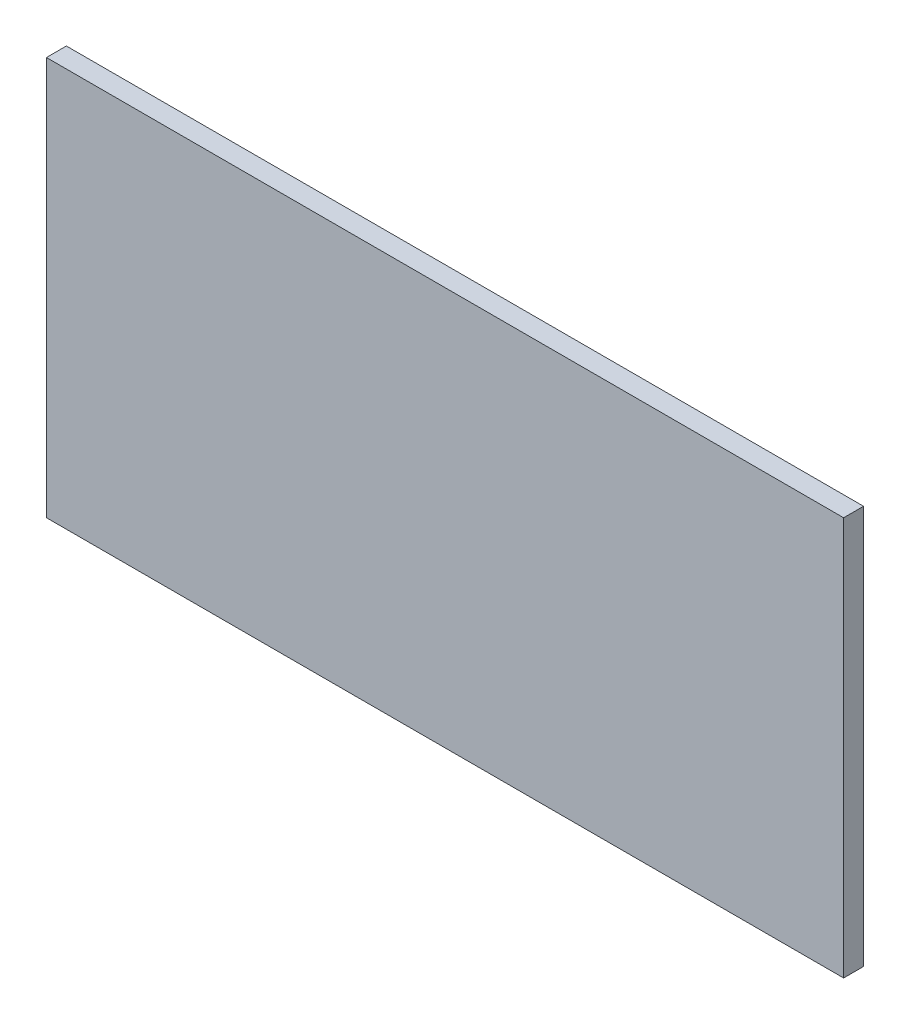
from build123d import *

# Parameters (mm, degrees)
SKETCH1_W           = 200
SKETCH1_H           = 100
BOSS_EXTRUDE1_DEPTH = 5


with BuildPart() as part:
    # Sketch1 → Boss-Extrude1 (new body)
    with BuildSketch(Plane.XY):
        Rectangle(SKETCH1_W, SKETCH1_H)
    extrude(amount=BOSS_EXTRUDE1_DEPTH)


solid = part.part
